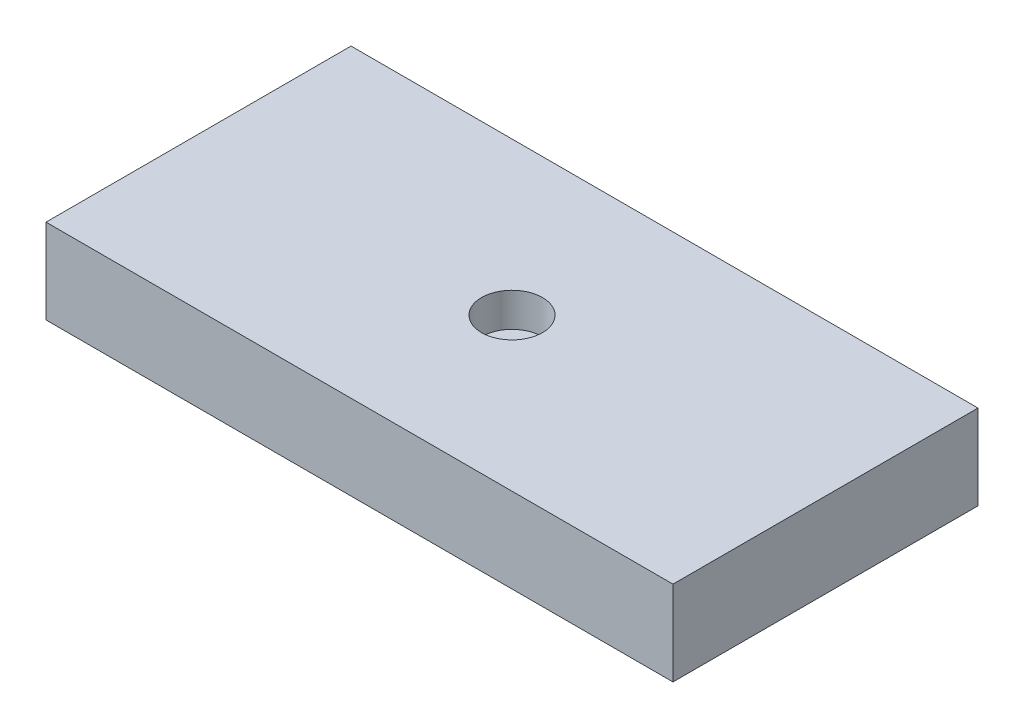
from build123d import *

# Parameters (mm, degrees)
SKETCH1_W           = 37
SKETCH1_H           = 18
BOSS_EXTRUDE1_DEPTH = 5
SKETCH2_R           = 1.796750317
CUT_EXTRUDE1_DEPTH  = 2


with BuildPart() as part:
    # Sketch1 → Boss-Extrude1 (new body)
    with BuildSketch(Plane(origin=(0, 0, 0), x_dir=(1, 0, 0), z_dir=(0, 1, 0))):
        Rectangle(SKETCH1_W, SKETCH1_H)
    extrude(amount=BOSS_EXTRUDE1_DEPTH)

    # Sketch2 → Cut-Extrude1 (cut)
    with BuildSketch(Plane(origin=(0, 5, 0), x_dir=(1, 0, 0), z_dir=(0, 1, 0))):
        Circle(SKETCH2_R)
    extrude(amount=-CUT_EXTRUDE1_DEPTH, mode=Mode.SUBTRACT)


solid = part.part
